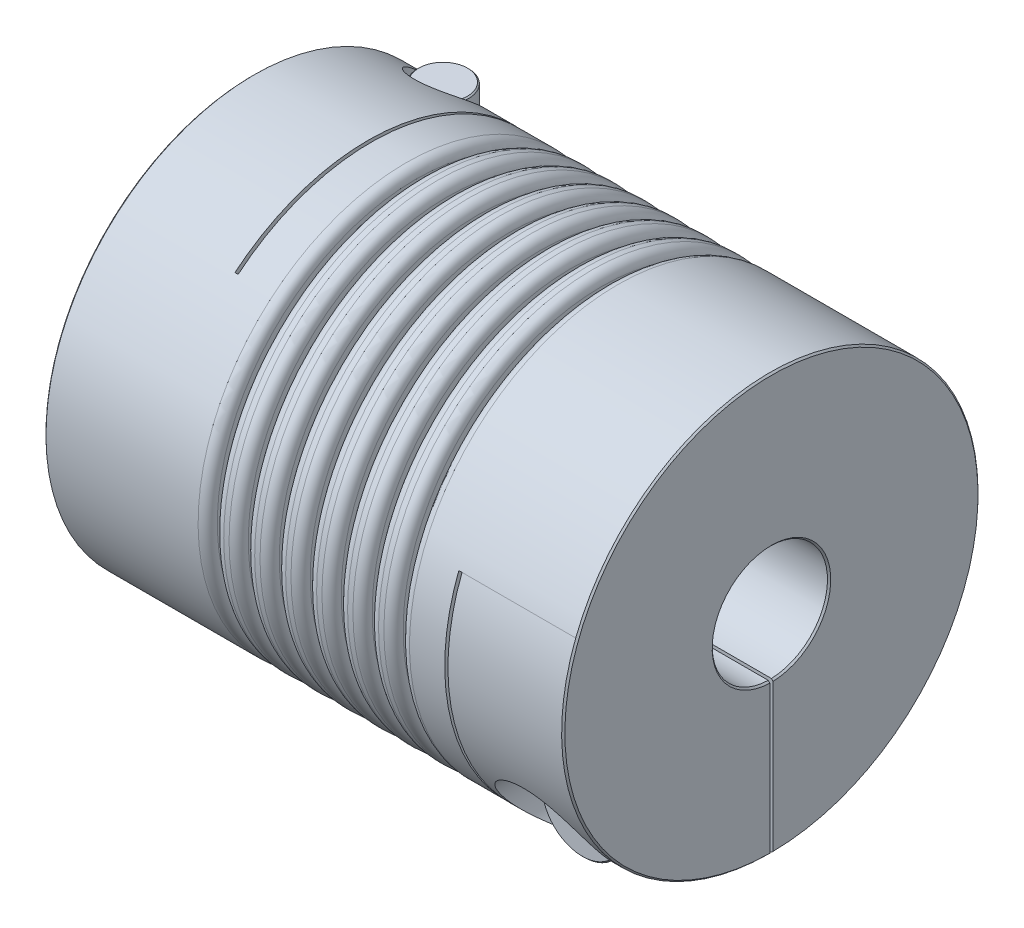
from build123d import *

# Parameters (mm, degrees)
SKETCH1_R                      = 32.5
BOSS_EXTRUDE1_DEPTH            = 40.5
SKETCH2_R                      = 9
CUT_EXTRUDE1_DEPTH             = 94.131627281
CHAMFER1_SIZE                  = 0.254
SKETCH4_W                      = 0.5
SKETCH4_H                      = 53.25
CUT_EXTRUDE2_DEPTH             = 84.195552766
SKETCH7_W                      = 0.5
SKETCH7_H                      = 44.25
CUT_EXTRUDE3_DEPTH             = 84.195552766
SKETCH8_W                      = 18
SKETCH8_H                      = 32.5
CUT_EXTRUDE5_DEPTH             = 0.25
SKETCH13_W                     = 18
SKETCH13_H                     = 32.5
CUT_EXTRUDE6_DEPTH             = 0.25
CBORE_FOR_M8_SHCS2_D           = 9
CBORE_FOR_M8_SHCS2_CBORE_D     = 15
CBORE_FOR_M8_SHCS2_CBORE_DEPTH = 20
CBORE_FOR_M8_SHCS1_D           = 9
CBORE_FOR_M8_SHCS1_CBORE_D     = 15
CBORE_FOR_M8_SHCS1_CBORE_DEPTH = 20
SKETCH16_R                     = 6.5
BOSS_EXTRUDE2_DEPTH            = 8
SKETCH17_R                     = 4
BOSS_EXTRUDE3_DEPTH            = 38
CHAMFER2_SIZE                  = 0.2
CUT_EXTRUDE7_DEPTH             = 1.5
CIRPATTERN1_COUNT              = 2
CIRPATTERN1_ANGLE              = 90
SKETCH19_W                     = 1
SKETCH19_H                     = 10
FILLET1_R                      = 1.5
FILLET2_R                      = 0.1


with BuildPart() as part:
    # Sketch1 → Boss-Extrude1 (new, symmetric)
    with BuildSketch(Plane(origin=(0, 0, 0), x_dir=(0, 0, -1), z_dir=(1, 0, 0))):
        Circle(SKETCH1_R)
    extrude(amount=BOSS_EXTRUDE1_DEPTH, both=True)

    # Sketch2 → Cut-Extrude1 (cut, through all)
    with BuildSketch(Plane(origin=(40.5, 0, 0), x_dir=(0, 0, -1), z_dir=(1, 0, 0))):
        Circle(SKETCH2_R)
    extrude(amount=-CUT_EXTRUDE1_DEPTH, mode=Mode.SUBTRACT)

    # Chamfer1
    chamfer1_edges = [part.edges().sort_by_distance(p)[0] for p in [
        (-40.5, 0, 32.5),
        (40.5, 0, 32.5),
        (-40.5, 0, 9),
        (40.5, 0, 9),
    ]]
    chamfer(chamfer1_edges, length=CHAMFER1_SIZE)

    # Sketch4 → Cut-Extrude2 (cut, through all)
    with BuildSketch(Plane.XZ.offset(32.5)):
        with Locations((-22.25, -5.875)):
            Rectangle(SKETCH4_W, SKETCH4_H)
    extrude(amount=-CUT_EXTRUDE2_DEPTH, mode=Mode.SUBTRACT)

    # Sketch7 → Cut-Extrude3 (cut, through all)
    with BuildSketch(Plane(origin=(0, 0, -32.5), x_dir=(-1, 0, 0), z_dir=(0, 0, -1))):
        with Locations((-22.25, -10.375)):
            Rectangle(SKETCH7_W, SKETCH7_H)
    extrude(amount=-CUT_EXTRUDE3_DEPTH, mode=Mode.SUBTRACT)

    # Sketch8 → Cut-Extrude5 (cut, symmetric)
    with BuildSketch(Plane(origin=(0, 0, 0), x_dir=(1, 0, 0), z_dir=(0, 1, 0))):
        with Locations((-31.5, 16.25)):
            Rectangle(SKETCH8_W, SKETCH8_H)
    extrude(amount=CUT_EXTRUDE5_DEPTH, both=True, mode=Mode.SUBTRACT)

    # Sketch13 → Cut-Extrude6 (cut, symmetric)
    with BuildSketch(Plane.XY):
        with Locations((31.5, -16.25)):
            Rectangle(SKETCH13_W, SKETCH13_H)
    extrude(amount=CUT_EXTRUDE6_DEPTH, both=True, mode=Mode.SUBTRACT)

    # CBORE for M8 SHCS2 (through all)
    with Locations(Plane.XZ.offset(32.5)):
        with Locations((-31.5, -20.747782778)):
            CounterBoreHole(CBORE_FOR_M8_SHCS2_D / 2, CBORE_FOR_M8_SHCS2_CBORE_D / 2, CBORE_FOR_M8_SHCS2_CBORE_DEPTH)

    # CBORE for M8 SHCS1 (through all)
    with Locations(Plane.XY.offset(32.5)):
        with Locations((31.5, -20.747782778)):
            CounterBoreHole(CBORE_FOR_M8_SHCS1_D / 2, CBORE_FOR_M8_SHCS1_CBORE_D / 2, CBORE_FOR_M8_SHCS1_CBORE_DEPTH)

    # Sketch19 → Cut-Revolve1 (revolve, cut)
    with BuildSketch(Plane.XY):
        with Locations((0, 27.5)):
            Rectangle(SKETCH19_W, SKETCH19_H)
        with Locations((4.833333333, 27.5)):
            Rectangle(SKETCH19_W, SKETCH19_H)
        with Locations((9.666666667, 27.5)):
            Rectangle(SKETCH19_W, SKETCH19_H)
        with Locations((14.5, 27.5)):
            Rectangle(SKETCH19_W, SKETCH19_H)
        with Locations((-14.5, 27.5)):
            Rectangle(SKETCH19_W, SKETCH19_H)
        with Locations((-9.666666667, 27.5)):
            Rectangle(SKETCH19_W, SKETCH19_H)
        with Locations((-4.833333333, 27.5)):
            Rectangle(SKETCH19_W, SKETCH19_H)
    revolve(axis=Axis((0, 0, 0), (-1, 0, 0)), mode=Mode.SUBTRACT)

    # Fillet1
    fillet1_edges = [part.edges().sort_by_distance(p)[0] for p in [
        (0.5, 0, 32.5),
        (-0.5, 0, 32.5),
        (-15, 0, 32.5),
        (-14, 0, 32.5),
        (5.333333333, 0, 32.5),
        (4.333333333, 0, 32.5),
        (10.166666667, 0, 32.5),
        (9.166666667, 0, 32.5),
        (15, 0, 32.5),
        (14, 0, 32.5),
        (-10.166666667, 0, 32.5),
        (-9.166666667, 0, 32.5),
        (-5.333333333, 0, 32.5),
        (-4.333333333, 0, 32.5),
    ]]
    fillet(fillet1_edges, radius=FILLET1_R)

    # Fillet2
    fillet2_edges = [part.edges().sort_by_distance(p)[0] for p in [
        (-0.5, -22.5, 0),
        (0.5, -22.5, 0),
        (-15, -22.5, 0),
        (-14, -22.5, 0),
        (4.333333333, -22.5, 0),
        (5.333333333, -22.5, 0),
        (9.166666667, -22.5, 0),
        (10.166666667, -22.5, 0),
        (14, -22.5, 0),
        (15, -22.5, 0),
        (-10.166666667, -22.5, 0),
        (-9.166666667, -22.5, 0),
        (-5.333333333, -22.5, 0),
        (-4.333333333, -22.5, 0),
    ]]
    fillet(fillet2_edges, radius=FILLET2_R)


with BuildPart() as body_2:
    # Sketch16 → Boss-Extrude2 (new body)
    with BuildSketch(Plane.XY.offset(12.5)):
        with Locations((31.5, -20.747782778)):
            Circle(SKETCH16_R)
    extrude(amount=BOSS_EXTRUDE2_DEPTH)

    # Sketch17 → Boss-Extrude3 (add)
    with BuildSketch(Plane(origin=(0, 0, 12.5), x_dir=(-1, 0, 0), z_dir=(0, 0, -1))):
        with Locations(Location((-31.5, -20.747782778, 0), (0, 0, 180))):
            Circle(SKETCH17_R)
    extrude(amount=BOSS_EXTRUDE3_DEPTH)

    # Chamfer2
    chamfer2_edges = [body_2.edges().sort_by_distance(p)[0] for p in [
        (25, -20.747782778, 12.5),
        (25, -20.747782778, 20.5),
        (27.5, -20.747782778, -25.5),
    ]]
    chamfer(chamfer2_edges, length=CHAMFER2_SIZE)

    # Sketch18 → Cut-Extrude7 (cut)
    with BuildSketch(Plane.XY.offset(20.5)):
        Polygon((31.5, -24.211884393), (34.5, -22.479833585), (34.5, -19.01573197), (31.5, -17.283681162), (28.5, -19.01573197), (28.5, -22.479833585), align=None)
    extrude(amount=-CUT_EXTRUDE7_DEPTH, mode=Mode.SUBTRACT)


with BuildPart() as body_3:
    # Mirror1: mirrored copy
    add(body_2.part.mirror(Plane(origin=(0, 0, 0), x_dir=(0, 0, 1), z_dir=(1, 0, 0))))


with BuildPart() as cirpattern1_1:
    # CirPattern1: pattern copy
    add(body_3.part.rotate(Axis((0, 0, 0), (1, 0, 0)), 1 * CIRPATTERN1_ANGLE / (CIRPATTERN1_COUNT - 1)))


solid = Compound([part.part, body_2.part, cirpattern1_1.part])
